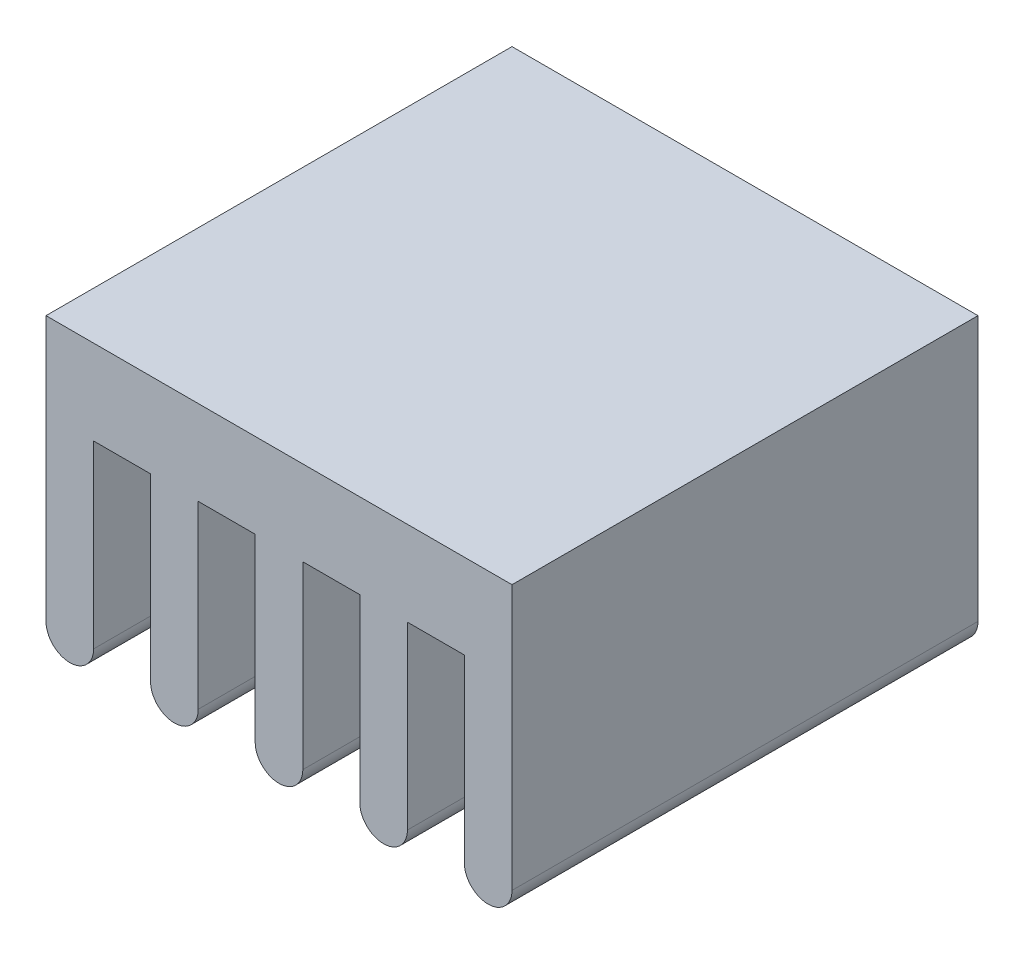
from build123d import *

# Parameters (mm, degrees)
RESSALTO_EXTRUS_O1_DEPTH = 4.4


with BuildPart() as part:
    # Esboço1 → Ressalto-extrusão1 (new body, symmetric)
    with BuildSketch(Plane.XY):
        with BuildLine():
            Line((0, 0), (8.8, 0))
            Line((8.8, 0), (8.8, -5))
            ThreePointArc((8.8, -5), (8.35, -5.45), (7.9, -5))
            Line((7.9, -5), (7.9, -1.6))
            Line((7.9, -1.6), (6.825, -1.6))
            Line((6.825, -1.6), (6.825, -5))
            ThreePointArc((6.825, -5), (6.375, -5.45), (5.925, -5))
            Line((5.925, -5), (5.925, -1.6))
            Line((5.925, -1.6), (4.85, -1.6))
            Line((4.85, -1.6), (4.85, -5))
            ThreePointArc((4.85, -5), (4.4, -5.45), (3.95, -5))
            Line((3.95, -5), (3.95, -1.6))
            Line((3.95, -1.6), (2.875, -1.6))
            Line((2.875, -1.6), (2.875, -5))
            ThreePointArc((2.875, -5), (2.425, -5.45), (1.975, -5))
            Line((1.975, -5), (1.975, -1.6))
            Line((1.975, -1.6), (0.9, -1.6))
            Line((0.9, -1.6), (0.9, -5))
            ThreePointArc((0.9, -5), (0.45, -5.45), (0, -5))
            Line((0, -5), (0, 0))
        make_face()
    extrude(amount=RESSALTO_EXTRUS_O1_DEPTH, both=True)


solid = part.part
